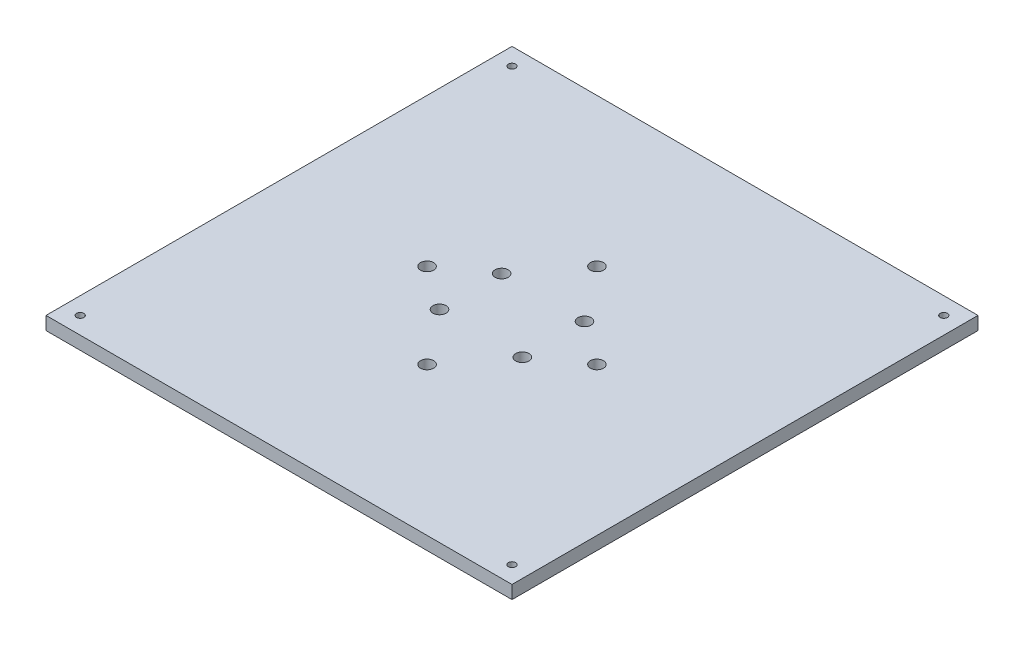
from build123d import *

# Parameters (mm, degrees)
SKETCH1_W           = 225
SKETCH1_H           = 225
BOSS_EXTRUDE1_DEPTH = 6.35
SKETCH2_R           = 1.75
CUT_EXTRUDE1_DEPTH  = 7.35
SKETCH3_R           = 3.175
CUT_EXTRUDE2_DEPTH  = 7.35


with BuildPart() as part:
    # Sketch1 → Boss-Extrude1 (new body)
    with BuildSketch(Plane(origin=(0, 0, 0), x_dir=(1, 0, 0), z_dir=(0, 1, 0))):
        with Locations((112.5, 112.5)):
            Rectangle(SKETCH1_W, SKETCH1_H)
    extrude(amount=BOSS_EXTRUDE1_DEPTH)

    # Sketch2 → Cut-Extrude1 (cut, through all)
    with BuildSketch(Plane(origin=(0, 6.35, 0), x_dir=(1, 0, 0), z_dir=(0, 1, 0))):
        with Locations((216.74, 216.74)):
            Circle(SKETCH2_R)
        with Locations((8.26, 216.74)):
            Circle(SKETCH2_R)
        with Locations((216.74, 8.26)):
            Circle(SKETCH2_R)
        with Locations((8.26, 8.26)):
            Circle(SKETCH2_R)
    extrude(amount=-CUT_EXTRUDE1_DEPTH, mode=Mode.SUBTRACT)

    # Sketch3 → Cut-Extrude2 (cut, through all)
    with BuildSketch(Plane(origin=(0, 6.35, 0), x_dir=(1, 0, 0), z_dir=(0, 1, 0))):
        with BuildLine():
            ThreePointArc((153.509619, 115.675), (150.334619, 112.5), (153.509619, 109.325))
            Line((153.509619, 109.325), (153.509619, 115.675))
        make_face()
        with BuildLine():
            Line((153.509619, 115.675), (153.509619, 109.325))
            ThreePointArc((153.509619, 109.325), (155.75468303, 110.25493597), (156.684619, 112.5))
            ThreePointArc((156.684619, 112.5), (155.75468303, 114.74506403), (153.509619, 115.675))
        make_face()
        with Locations((132.5, 127.5)):
            Circle(SKETCH3_R)
        with Locations((132.5, 97.5)):
            Circle(SKETCH3_R)
        with Locations((92.5, 97.5)):
            Circle(SKETCH3_R)
        with Locations((92.5, 127.5)):
            Circle(SKETCH3_R)
        with BuildLine():
            ThreePointArc((71.490381, 115.675), (68.315381, 112.5), (71.490381, 109.325))
            Line((71.490381, 109.325), (71.490381, 115.675))
        make_face()
        with BuildLine():
            Line((71.490381, 115.675), (71.490381, 109.325))
            ThreePointArc((71.490381, 109.325), (73.73544503, 110.25493597), (74.665381, 112.5))
            ThreePointArc((74.665381, 112.5), (73.73544503, 114.74506403), (71.490381, 115.675))
        make_face()
        with BuildLine():
            ThreePointArc((109.325, 153.509619), (112.5, 150.334619), (115.675, 153.509619))
            Line((115.675, 153.509619), (109.325, 153.509619))
        make_face()
        with BuildLine():
            Line((109.325, 153.509619), (115.675, 153.509619))
            ThreePointArc((115.675, 153.509619), (112.5, 156.684619), (109.325, 153.509619))
        make_face()
        with BuildLine():
            ThreePointArc((109.325, 71.490381), (112.5, 68.315381), (115.675, 71.490381))
            Line((115.675, 71.490381), (109.325, 71.490381))
        make_face()
        with BuildLine():
            Line((109.325, 71.490381), (115.675, 71.490381))
            ThreePointArc((115.675, 71.490381), (112.5, 74.665381), (109.325, 71.490381))
        make_face()
    extrude(amount=-CUT_EXTRUDE2_DEPTH, mode=Mode.SUBTRACT)


solid = part.part
